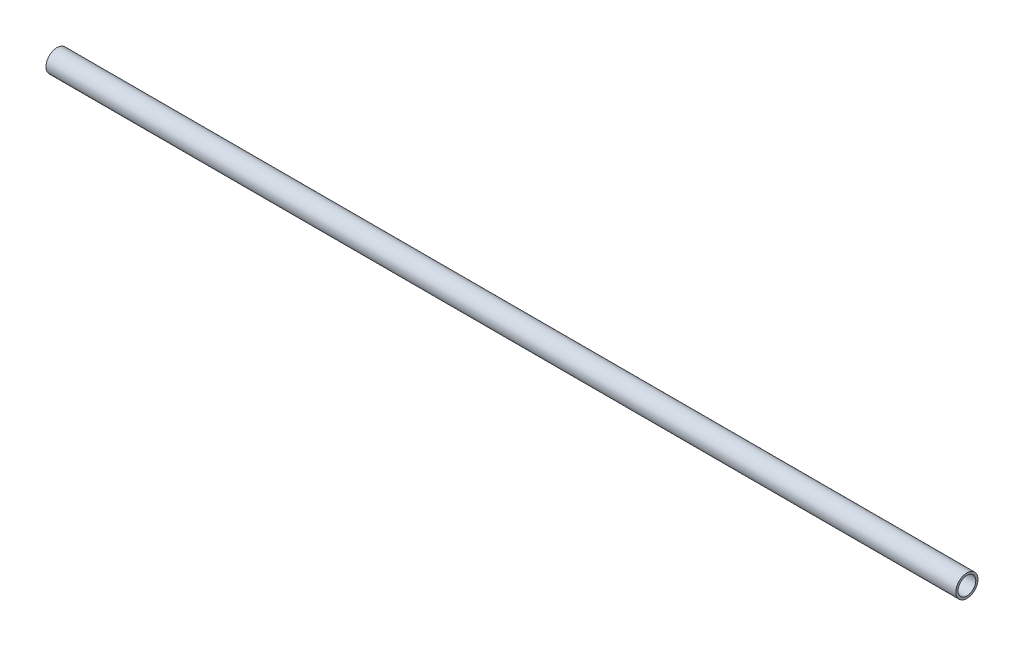
from build123d import *

# Parameters (mm, degrees)
SKETCH_1_R      = 5
SKETCH_1_R_2    = 4
EXTRUDE_1_DEPTH = 410


with BuildPart() as part:
    # 草图1 → 凸台-拉伸1 (new body)
    with BuildSketch(Plane(origin=(0, 0, 0), x_dir=(0, 0, -1), z_dir=(1, 0, 0))):
        Circle(SKETCH_1_R)
        Circle(SKETCH_1_R_2, mode=Mode.SUBTRACT)
    extrude(amount=EXTRUDE_1_DEPTH)


solid = part.part
